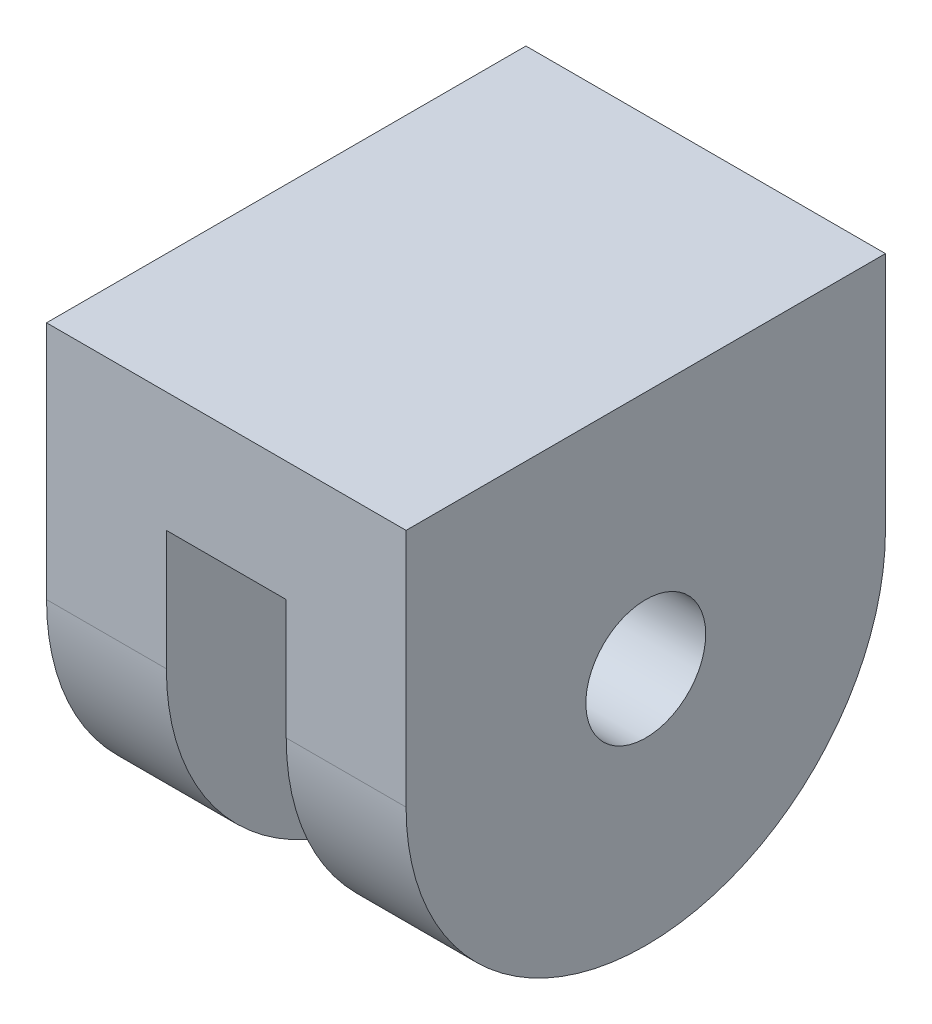
from build123d import *

# Parameters (mm, degrees)
MOUNT_DEPTH                      = 9.525
SKETCH2_W                        = 6.35
SKETCH2_H                        = 19.05
CENTER_CUTOUT_FOR_RIB_DEPTH      = 13.7
CENTER_CUTOUT_FOR_RIB_DEPTH_BACK = 13.7
SKETCH3_R                        = 3.175
PIN_HOLE_DEPTH                   = 10.525
PIN_HOLE_DEPTH_BACK              = 10.525


with BuildPart() as part:
    # Sketch1 → mount (new body, symmetric)
    with BuildSketch(Plane(origin=(0, 0, 0), x_dir=(0, 0, -1), z_dir=(1, 0, 0))):
        with BuildLine():
            Line((12.7, 0), (12.7, -12.7))
            ThreePointArc((12.7, -12.7), (0, -25.4), (-12.7, -12.7))
            Line((-12.7, -12.7), (-12.7, 0))
            Line((-12.7, 0), (12.7, 0))
        make_face()
    extrude(amount=MOUNT_DEPTH, both=True)

    # Sketch2 → center cutout for rib (cut, two sides)
    with BuildSketch(Plane.XY) as center_cutout_for_rib_sk:
        with Locations((0, -15.875)):
            Rectangle(SKETCH2_W, SKETCH2_H)
    extrude(amount=CENTER_CUTOUT_FOR_RIB_DEPTH, mode=Mode.SUBTRACT)
    extrude(center_cutout_for_rib_sk.sketch, amount=-CENTER_CUTOUT_FOR_RIB_DEPTH_BACK, mode=Mode.SUBTRACT)

    # Sketch3 → pin hole (cut, two sides)
    with BuildSketch(Plane(origin=(0, 0, 0), x_dir=(0, 0, -1), z_dir=(1, 0, 0))) as pin_hole_sk:
        with Locations((0, -12.7)):
            Circle(SKETCH3_R)
    extrude(amount=PIN_HOLE_DEPTH, mode=Mode.SUBTRACT)
    extrude(pin_hole_sk.sketch, amount=-PIN_HOLE_DEPTH_BACK, mode=Mode.SUBTRACT)


solid = part.part
